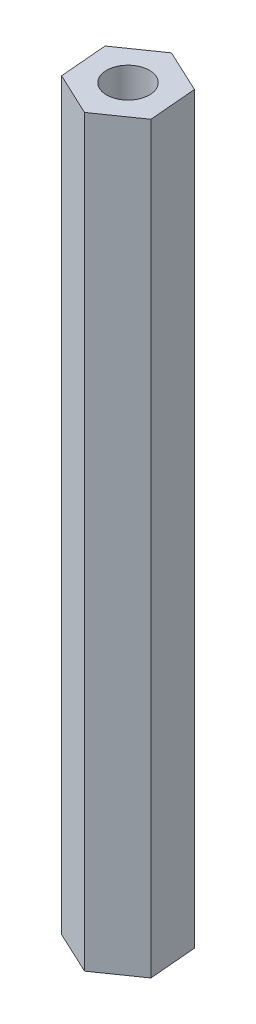
from build123d import *

# Parameters (mm, degrees)
BOSS_EXTRUDE1_DEPTH = 57.15
SKETCH2_R           = 3.2893
CUT_EXTRUDE1_DEPTH  = 12.7


with BuildPart() as part:
    # Sketch1 → Boss-Extrude1 (new body, symmetric)
    with BuildSketch(Plane(origin=(0, 0, 0), x_dir=(1, 0, 0), z_dir=(0, 1, 0))):
        Polygon((6.016541477, 4.191009662), (-0.621250096, 7.305982593), (-6.637791573, 3.114972932), (-6.016541477, -4.191009662), (0.621250096, -7.305982593), (6.637791573, -3.114972932), align=None)
    extrude(amount=BOSS_EXTRUDE1_DEPTH, both=True)

    # Sketch2 → Cut-Extrude1 (cut)
    with BuildSketch(Plane(origin=(0, 57.15, 0), x_dir=(1, 0, 0), z_dir=(0, 1, 0))):
        Circle(SKETCH2_R)
    cut_extrude1 = extrude(amount=-CUT_EXTRUDE1_DEPTH, mode=Mode.SUBTRACT)

    # Mirror1: Cut-Extrude1 across plane
    add(cut_extrude1.mirror(Plane.ZX), mode=Mode.SUBTRACT)


solid = part.part
